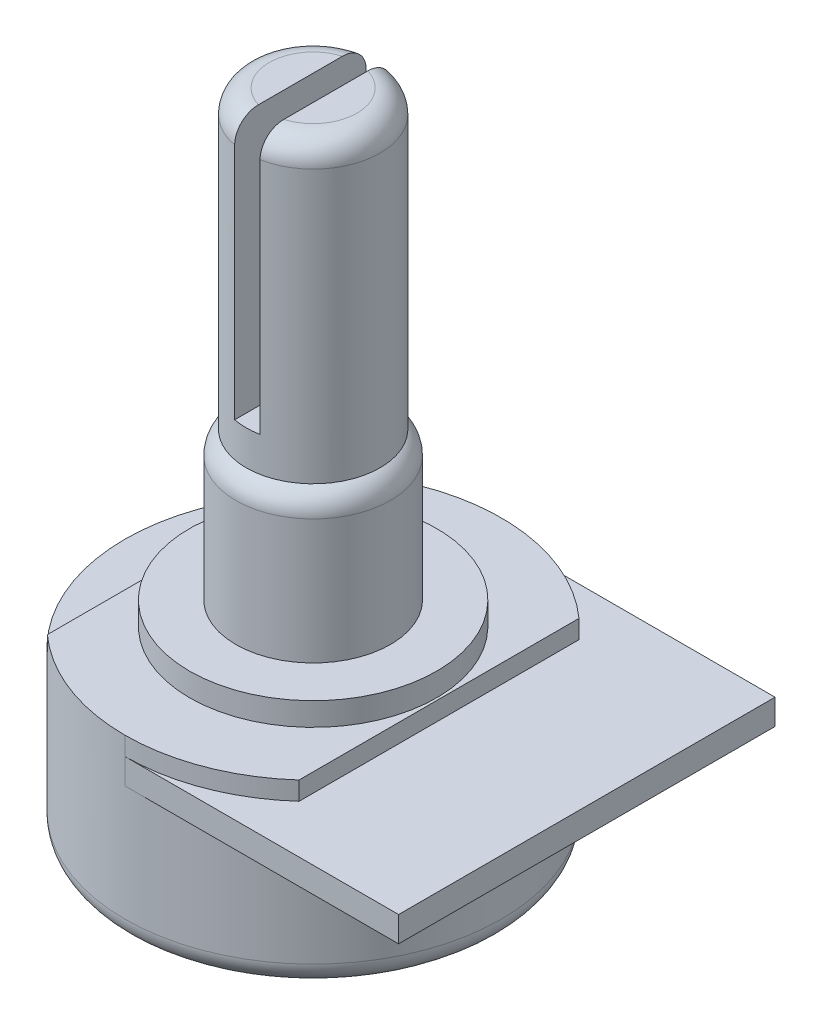
from build123d import *

# Parameters (mm, degrees)
SKETCH1_R           = 8.149999999999999
BOSS_EXTRUDE1_DEPTH = 6
BOSS_EXTRUDE2_DEPTH = 1.1
BOSS_EXTRUDE3_DEPTH = 0.8
SKETCH4_R           = 5.35
BOSS_EXTRUDE4_DEPTH = 1
SKETCH5_R           = 3.35
BOSS_EXTRUDE5_DEPTH = 6.4
FILLET1_R           = 1
SKETCH6_R           = 2.9
BOSS_EXTRUDE6_DEPTH = 12.8
CUT_EXTRUDE1_DEPTH  = 11.3
FILLET2_R           = 1


with BuildPart() as part:
    # Sketch1 → Boss-Extrude1 (new body)
    with BuildSketch(Plane(origin=(0, 0, 0), x_dir=(1, 0, 0), z_dir=(0, 1, 0))):
        with Locations(Location((0, 0, 0), (0, 0, 270))):
            Circle(SKETCH1_R)
    extrude(amount=BOSS_EXTRUDE1_DEPTH)

    # Sketch2 → Boss-Extrude2 (add)
    with BuildSketch(Plane(origin=(0, 6, 0), x_dir=(1, 0, 0), z_dir=(0, 1, 0))):
        with BuildLine():
            Line((0, -8.15), (11.85, -8.15))
            Line((11.85, -8.15), (11.849999999999996, 8.150000000000004))
            Line((11.849999999999996, 8.150000000000004), (0, 8.15))
            ThreePointArc((0, 8.15), (-8.15, 1e-15), (0, -8.15))
        make_face()
    extrude(amount=BOSS_EXTRUDE2_DEPTH)

    # Sketch3 → Boss-Extrude3 (add)
    with BuildSketch(Plane(origin=(0, 7.1000000000000005, 0), x_dir=(1, 0, 0), z_dir=(0, 1, 0))):
        with BuildLine():
            Line((-5.45, 6.059702963017249), (-5.45, -6.059702963017249))
            ThreePointArc((-5.45, -6.059702963017249), (-1.31e-15, -8.150000000000002), (5.45, -6.059702963017249))
            Line((5.45, -6.059702963017249), (5.45, 6.059702963017249))
            ThreePointArc((5.45, 6.059702963017249), (5e-16, 8.150000000000002), (-5.45, 6.059702963017249))
        make_face()
    extrude(amount=BOSS_EXTRUDE3_DEPTH)

    # Sketch4 → Boss-Extrude4 (add)
    with BuildSketch(Plane(origin=(0, 7.9, 0), x_dir=(1, 0, 0), z_dir=(0, 1, 0))):
        with Locations(Location((0, 0, 0), (0, 0, 270))):
            Circle(SKETCH4_R)
    extrude(amount=BOSS_EXTRUDE4_DEPTH)

    # Sketch5 → Boss-Extrude5 (add)
    with BuildSketch(Plane(origin=(0, 8.900000000000002, 0), x_dir=(1, 0, 0), z_dir=(0, 1, 0))):
        with Locations(Location((0, 0, 0), (0, 0, 270))):
            Circle(SKETCH5_R)
    extrude(amount=BOSS_EXTRUDE5_DEPTH)

    # Fillet1
    fillet1_edges = [part.edges().sort_by_distance(p)[0] for p in [
        (2.5e-15, 0, -8.149999999999999),
        (1.03e-15, 15.300000000000002, -3.35),
    ]]
    fillet(fillet1_edges, radius=FILLET1_R)

    # Sketch6 → Boss-Extrude6 (add)
    with BuildSketch(Plane(origin=(0, 15.3, 0), x_dir=(1, 0, 0), z_dir=(0, 1, 0))):
        with Locations(Location((0, 0, 0), (0, 0, 270))):
            Circle(SKETCH6_R)
    extrude(amount=BOSS_EXTRUDE6_DEPTH)

    # Sketch7 → Cut-Extrude1 (cut)
    with BuildSketch(Plane(origin=(0, 28.1, 0), x_dir=(1, 0, 0), z_dir=(0, 1, 0))):
        Polygon((0.5499999999999995, 5.000000000000001), (-0.5500000000000006, 5.000000000000001), (-0.5499999999999994, -4.999999999999999), (0.5500000000000007, -4.999999999999999), align=None)
    extrude(amount=-CUT_EXTRUDE1_DEPTH, mode=Mode.SUBTRACT)

    # Fillet2
    fillet2_edges = [part.edges().sort_by_distance(p)[0] for p in [
        (2.9, 28.1, 7.347e-14),
        (-2.9, 28.1, 7.105e-14),
    ]]
    fillet(fillet2_edges, radius=FILLET2_R)


solid = part.part
